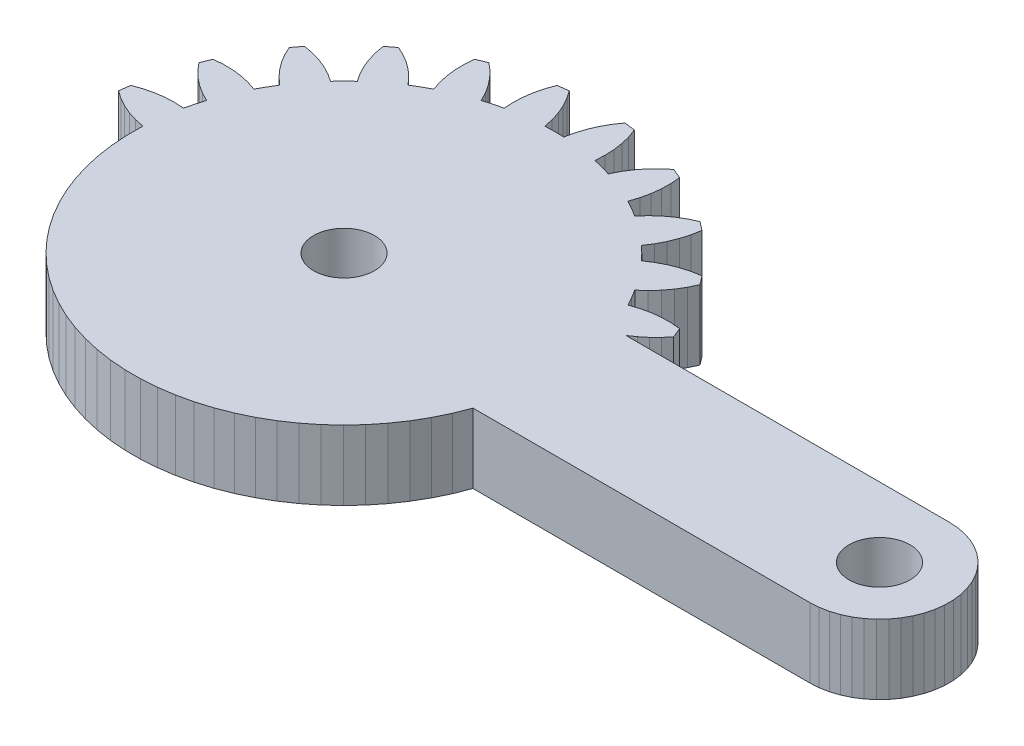
from build123d import *

# Parameters (mm, degrees)
SKETCH1_R           = 1.750002173
SKETCH1_R_2         = 1.750003067
BOSS_EXTRUDE1_DEPTH = 4.00000019


with BuildPart() as part:
    # Sketch1 → Boss-Extrude1 (new body)
    with BuildSketch(Plane.XZ):
        Polygon((8.608905599, 1.68648304), (8.653514087, 1.148083946), (9.230175056, 0.909223221), (9.642423131, 1.25838595), (10.017720051, 1.646994962), (10.352309793, 2.071157098), (10.642839596, 2.526629949), (10.886410251, 3.008852014), (11.407479644, 2.856614999), (11.934859678, 2.727918094), (11.904690415, 2.188517945), (11.928560212, 1.64880103), (12.006239966, 1.114172046), (12.136950158, 0.589979813), (12.319389731, 0.081471168), (12.938220054, 0), (13.246050104, 0.443963305), (13.507979922, 0.916464312), (13.721389696, 1.412771991), (13.884129934, 1.927918987), (13.994590379, 2.456750022), (14.537310228, 2.444565063), (15.080040321, 2.456750022), (15.190499835, 1.927918987), (15.353240073, 1.412771991), (15.566649847, 0.916464312), (15.828579664, 0.443963305), (16.136409715, 0), (16.755240038, 0.081471168), (16.937680542, 0.589979813), (17.068389803, 1.114172046), (17.146069556, 1.64880103), (17.169939354, 2.188517945), (17.139770091, 2.727918094), (17.667150125, 2.856614999), (18.188219517, 3.008852014), (18.431790173, 2.526629949), (18.722319975, 2.071157098), (19.056910649, 1.646994962), (19.432209432, 1.25838595), (19.84445937, 0.909223221), (20.421119407, 1.148083946), (20.465720445, 1.68648304), (20.456310362, 2.226644894), (20.392969251, 2.763161901), (20.276339725, 3.290666966), (20.107589662, 3.803876927), (20.583689213, 4.064687062), (21.04761079, 4.346599802), (21.407680586, 3.943847958), (21.806199104, 3.579091048), (22.239169106, 3.255978925), (22.702259943, 2.977746073), (23.190829903, 2.747178078), (23.686019704, 3.127150936), (23.589760065, 3.65874893), (23.440860212, 4.178069998), (23.240819573, 4.679913167), (22.991629317, 5.159256049), (22.69580029, 5.611301865), (23.088179529, 5.986448843), (23.4633293, 6.378828082), (23.915370926, 6.082994863), (24.394720793, 5.833810195), (24.896560237, 5.633769091), (25.415880606, 5.484871101), (25.947479531, 5.388610996), (26.327449828, 5.883802194), (26.096880436, 6.372373085), (25.818649679, 6.835460197), (25.495540351, 7.268427871), (25.130780414, 7.666944992), (24.728029966, 8.027019911), (25.009939447, 8.490939625), (25.270750746, 8.967043832), (25.783959776, 8.798288181), (26.311470196, 8.681657724), (26.847980917, 8.618320338), (27.388149872, 8.608905599), (27.926549315, 8.653513156), (28.165409341, 9.230175056), (27.851330116, 9.60460864), (27.504689991, 9.949113242), (27.128310874, 10.260869749), (26.725299656, 10.537319817), (45.287318528, 10.537319817), (45.78864947, 10.568859987), (46.28207162, 10.662980378), (46.759821475, 10.81821043), (47.214329243, 11.032089591), (47.638449818, 11.301250197), (48.025511205, 11.621439829), (48.369370401, 11.987620033), (48.664629459, 12.394010089), (48.906620592, 12.834199704), (49.091540277, 13.301249593), (49.216460437, 13.787790202), (49.279421568, 14.286150225), (49.279421568, 14.788479544), (49.216460437, 15.286839567), (49.091540277, 15.773380175), (48.906620592, 16.240429133), (48.664629459, 16.680620611), (48.369370401, 17.087010667), (48.025511205, 17.453189939), (47.638449818, 17.773380503), (47.214329243, 18.042540178), (46.759821475, 18.25642027), (46.28207162, 18.411649391), (45.78864947, 18.505770713), (45.287318528, 18.537320197), (25.949349627, 18.537320197), (25.617640465, 19.380990416), (25.223650038, 20.197430626), (24.769600481, 20.982069895), (24.258049205, 21.730499342), (23.691879585, 22.438490763), (23.074250668, 23.102089763), (22.408649325, 23.717539385), (21.698819473, 24.281419814), (20.948730409, 24.790529162), (20.16261965, 25.242010131), (19.34489049, 25.633340701), (18.50014925, 25.962309912), (17.633130774, 26.227079332), (16.74872078, 26.426149532), (15.851879492, 26.5583992), (14.947650023, 26.623100042), (14.041109942, 26.619879529), (13.137370348, 26.548760012), (12.241490185, 26.410130784), (11.358509772, 26.204779744), (10.493399575, 25.93385987), (9.65101365, 25.598900393), (8.836088702, 25.201769546), (8.053204045, 24.744709954), (7.306755986, 24.230280891), (6.600946188, 23.661380634), (5.9397351, 23.041209206), (5.326842889, 22.373240441), (4.765709862, 21.661240608), (4.259493202, 20.909199491), (3.811036935, 20.121360198), (3.422857961, 19.302129745), (3.097143024, 18.456129357), (2.83572101, 17.588099465), (2.64005689, 16.702920198), (2.511255909, 15.805579722), (2.45003798, 14.901109971), (2.456750954, 13.994590379), (1.927920035, 13.884129934), (1.412771991, 13.721389696), (0.916464312, 13.507979922), (0.443963305, 13.246050104), (0, 12.938220054), (0.081472099, 12.319389731), (0.589979813, 12.136950158), (1.114172977, 12.006239966), (1.648801961, 11.928560212), (2.188519109, 11.904690415), (2.727918094, 11.934859678), (2.856615931, 11.407479644), (3.008852014, 10.886400007), (2.526629949, 10.642839596), (2.071157098, 10.352309793), (1.64699601, 10.017720051), (1.25838595, 9.642422199), (0.90922229, 9.230175056), (1.148083946, 8.653513156), (1.686483971, 8.608905599), (2.226644894, 8.618320338), (2.763163066, 8.681657724), (3.290666034, 8.798288181), (3.803876927, 8.967043832), (4.064687062, 8.490939625), (4.346599802, 8.027019911), (3.943848889, 7.666944992), (3.579091048, 7.268427871), (3.255980089, 6.835460197), (2.977747004, 6.372373085), (2.747178078, 5.883802194), (3.1271521, 5.388610996), (3.65874893, 5.484871101), (4.178069998, 5.633769091), (4.679913167, 5.833810195), (5.15925698, 6.082994863), (5.611301865, 6.378828082), (5.986449774, 5.986448843), (6.378828082, 5.611301865), (6.082994863, 5.159256049), (5.833810195, 4.679913167), (5.63376816, 4.178069998), (5.484871101, 3.65874893), (5.388611928, 3.127150936), (5.883802194, 2.747178078), (6.372374017, 2.977746073), (6.835461129, 3.255978925), (7.268428802, 3.579091048), (7.666944992, 3.943847958), (8.027019911, 4.346599802), (8.490939625, 4.064687062), (8.967043832, 3.803876927), (8.798288181, 3.290666966), (8.681658655, 2.763161901), (8.618320338, 2.226644894), align=None)
        with Locations((14.543747241, 14.53559185)):
            Circle(SKETCH1_R, mode=Mode.SUBTRACT)
        with Locations((45.287314802, 14.53731656)):
            Circle(SKETCH1_R_2, mode=Mode.SUBTRACT)
    extrude(amount=-BOSS_EXTRUDE1_DEPTH)


solid = part.part
